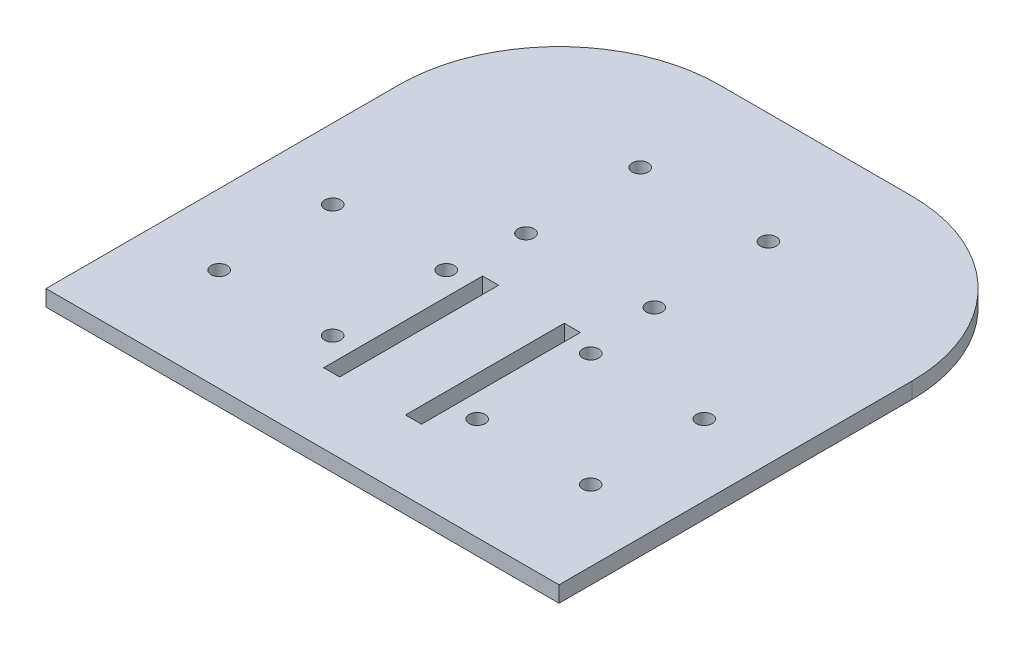
from build123d import *

# Parameters (mm, degrees)
SKETCH1_W           = 203.2
SKETCH1_H           = 203.2
BOSS_EXTRUDE1_DEPTH = 6.35
CUT_EXTRUDE1_DEPTH  = 7.35
SKETCH10_R          = 3.175
SKETCH10_W          = 6.35
SKETCH10_H          = 62.924217451
CUT_EXTRUDE4_DEPTH  = 7.35


with BuildPart() as part:
    # Sketch1 → Boss-Extrude1 (new body)
    with BuildSketch(Plane(origin=(0, 0, 0), x_dir=(1, 0, 0), z_dir=(0, 1, 0))):
        Rectangle(SKETCH1_W, SKETCH1_H)
    extrude(amount=BOSS_EXTRUDE1_DEPTH)

    # Sketch2 → Cut-Extrude1 (cut, through all)
    with BuildSketch(Plane(origin=(0, 6.35, 0), x_dir=(1, 0, 0), z_dir=(0, 1, 0))):
        with BuildLine():
            Line((101.6, 38.1), (101.6, 101.6))
            Line((101.6, 101.6), (38.1, 101.6))
            ThreePointArc((38.1, 101.6), (83.001280605, 83.001280605), (101.6, 38.1))
        make_face()
        with BuildLine():
            Line((-38.1, 101.6), (-101.6, 101.6))
            Line((-101.6, 101.6), (-101.6, 38.1))
            ThreePointArc((-101.6, 38.1), (-83.001280605, 83.001280605), (-38.1, 101.6))
        make_face()
    extrude(amount=-CUT_EXTRUDE1_DEPTH, mode=Mode.SUBTRACT)

    # Sketch10 → Cut-Extrude4 (cut, through all)
    with BuildSketch(Plane.XZ):
        with Locations((25.309743879, -12.40083867)):
            Circle(SKETCH10_R)
        with Locations((-25.490256121, -12.40083867)):
            Circle(SKETCH10_R)
        with Locations((-25.490256121, -57.61283867)):
            Circle(SKETCH10_R)
        with Locations((25.309743879, -57.61283867)):
            Circle(SKETCH10_R)
        with Locations((-73.66, 16.002)):
            Circle(SKETCH10_R)
        with Locations((-73.66, 60.965705209)):
            Circle(SKETCH10_R)
        with Locations((-28.696294791, 60.965705209)):
            Circle(SKETCH10_R)
        with Locations((-28.696294791, 16.002)):
            Circle(SKETCH10_R)
        with Locations((28.515782549, 60.965705209)):
            Circle(SKETCH10_R)
        with Locations((73.479487758, 60.965705209)):
            Circle(SKETCH10_R)
        with Locations((73.479487758, 16.002)):
            Circle(SKETCH10_R)
        with Locations((28.515782549, 16.002)):
            Circle(SKETCH10_R)
        with Locations((-16.28703867, 42.293852605)):
            Rectangle(SKETCH10_W, SKETCH10_H)
        with Locations((16.106526428, 42.293852605)):
            Rectangle(SKETCH10_W, SKETCH10_H)
    extrude(amount=-CUT_EXTRUDE4_DEPTH, mode=Mode.SUBTRACT)


solid = part.part
